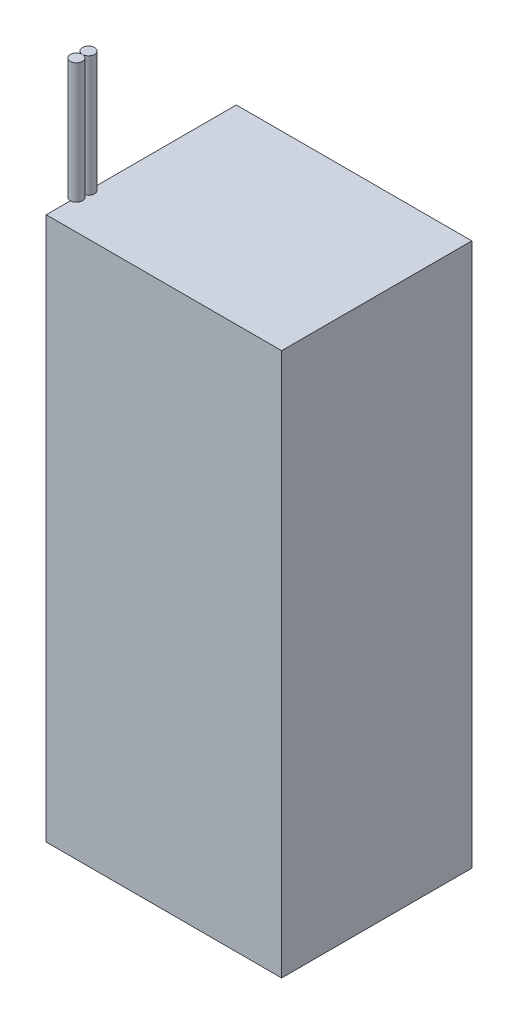
from build123d import *

# Parameters (mm, degrees)
SKETCH1_W           = 78
SKETCH1_H           = 63
BOSS_EXTRUDE1_DEPTH = 180
BOSS_EXTRUDE4_DEPTH = 40


with BuildPart() as part:
    # Sketch1 → Boss-Extrude1 (new body)
    with BuildSketch(Plane(origin=(0, 0, 0), x_dir=(1, 0, 0), z_dir=(0, 1, 0))):
        Rectangle(SKETCH1_W, SKETCH1_H)
    extrude(amount=BOSS_EXTRUDE1_DEPTH)


with BuildPart() as body_2:
    # Sketch2 → Boss-Extrude4 (new body)
    with BuildSketch(Plane(origin=(0, 180, 0), x_dir=(1, 0, 0), z_dir=(0, 1, 0))):
        with BuildLine():
            ThreePointArc((-39, -23.5), (-37.585786438, -22.914213562), (-37, -21.5))
            ThreePointArc((-37, -21.5), (-37.585786438, -20.085786438), (-39, -19.5))
            Line((-39, -19.5), (-39, -23.5))
        make_face()
        with BuildLine():
            Line((-39, -23.5), (-39, -19.5))
            ThreePointArc((-39, -19.5), (-41, -21.5), (-39, -23.5))
        make_face()
        with BuildLine():
            ThreePointArc((-39, -15.5), (-41, -17.5), (-39, -19.5))
            Line((-39, -19.5), (-39, -15.5))
        make_face()
        with BuildLine():
            Line((-39, -15.5), (-39, -19.5))
            ThreePointArc((-39, -19.5), (-37.585786438, -18.914213562), (-37, -17.5))
            ThreePointArc((-37, -17.5), (-37.585786438, -16.085786438), (-39, -15.5))
        make_face()
    extrude(amount=BOSS_EXTRUDE4_DEPTH)


solid = Compound([part.part, body_2.part])
